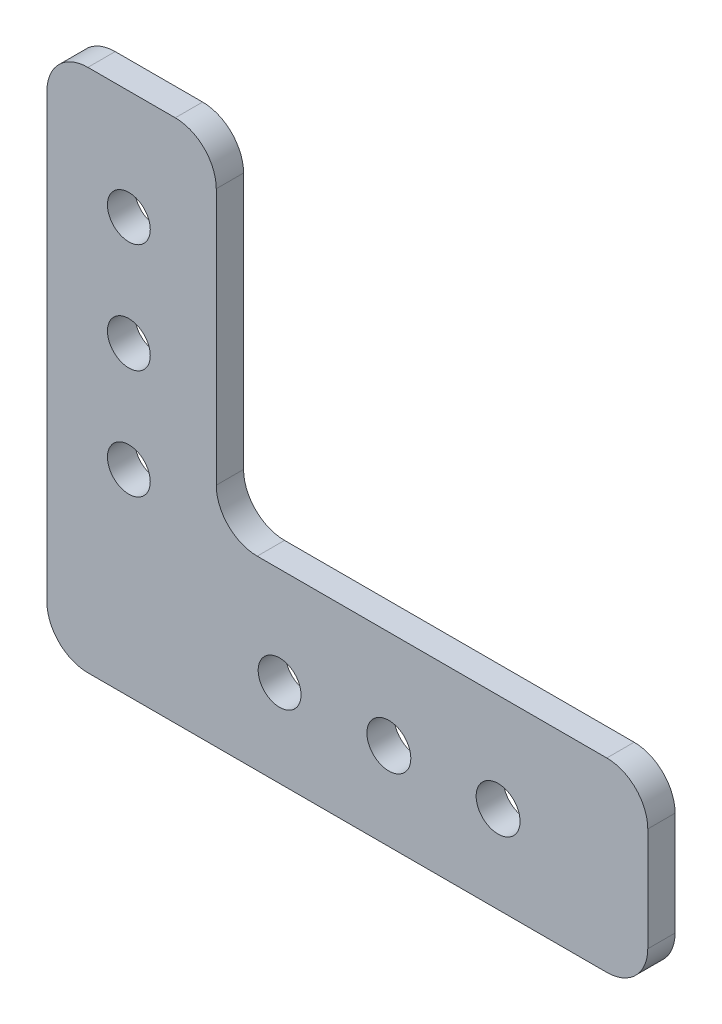
from build123d import *

# Parameters (mm, degrees)
SKETCH1_R           = 2.4892
SKETCH1_R_2         = 2.5527
BOSS_EXTRUDE1_DEPTH = 3.175
SKETCH2_W           = 4.445
SKETCH2_H           = 39.37
CUT_EXTRUDE1_DEPTH  = 4.175
FILLET2_R           = 4.7625


with BuildPart() as part:
    # Sketch1 → Boss-Extrude1 (new body)
    with BuildSketch(Plane.XY):
        Polygon((-34.925, 31.75), (-34.925, -29.21), (34.925, -29.21), (34.925, -7.62), (-10.795, -7.62), (-10.795, 31.75), align=None)
        with Locations((-25.4, -19.05)):
            Circle(SKETCH1_R, mode=Mode.SUBTRACT)
        with Locations((-7.874, -19.05)):
            Circle(SKETCH1_R, mode=Mode.SUBTRACT)
        with Locations((-25.4, -6.35)):
            Circle(SKETCH1_R, mode=Mode.SUBTRACT)
        with Locations((4.826, -19.05)):
            Circle(SKETCH1_R_2, mode=Mode.SUBTRACT)
        with Locations((17.526, -19.05)):
            Circle(SKETCH1_R_2, mode=Mode.SUBTRACT)
        with Locations((-25.4, 6.35)):
            Circle(SKETCH1_R, mode=Mode.SUBTRACT)
        with Locations((-25.4, 19.05)):
            Circle(SKETCH1_R, mode=Mode.SUBTRACT)
        with Locations((-25.4, -19.05)):
            Circle(SKETCH1_R)
    extrude(amount=BOSS_EXTRUDE1_DEPTH)

    # Sketch2 → Cut-Extrude1 (cut, through all)
    with BuildSketch(Plane.XY.offset(3.175)):
        with Locations((-13.0175, 12.065)):
            Rectangle(SKETCH2_W, SKETCH2_H)
    extrude(amount=-CUT_EXTRUDE1_DEPTH, mode=Mode.SUBTRACT)

    # Fillet2
    fillet2_edges = [part.edges().sort_by_distance(p)[0] for p in [
        (-34.925, 31.75, 1.5875),
        (34.925, -7.62, 1.5875),
        (34.925, -29.21, 1.5875),
        (-34.925, -29.21, 1.5875),
        (-15.24, -7.62, 1.5875),
        (-15.24, 31.75, 1.5875),
    ]]
    fillet(fillet2_edges, radius=FILLET2_R)


solid = part.part
